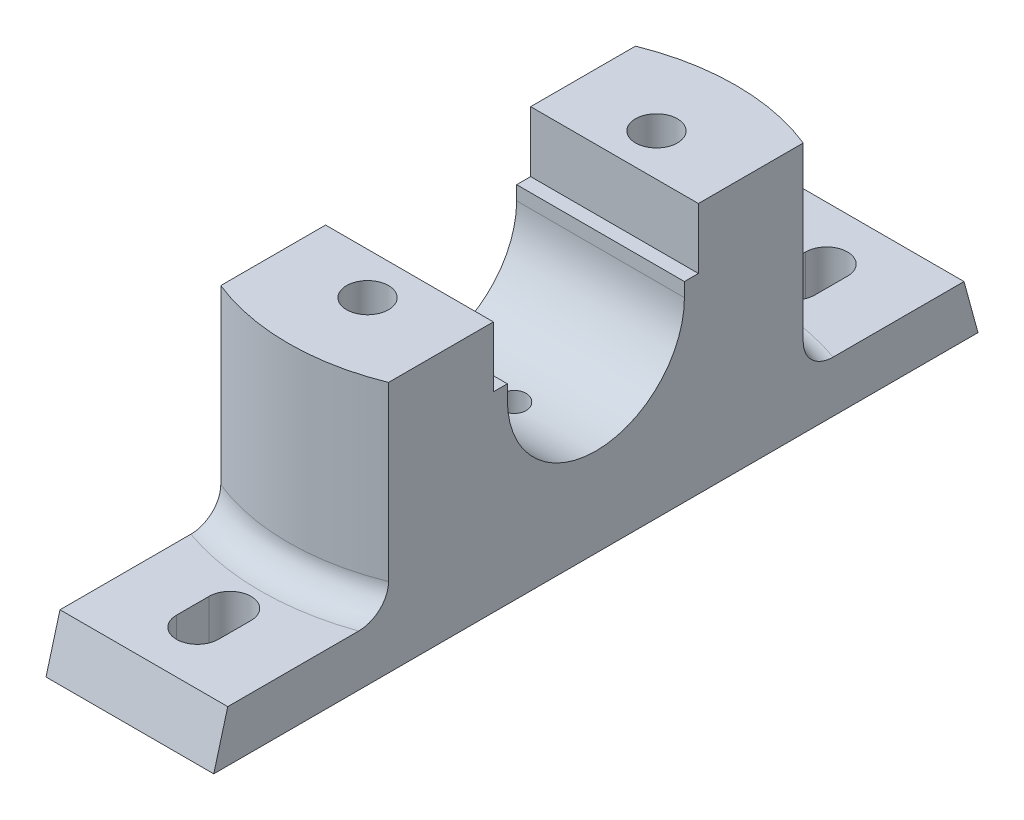
from build123d import *

# Parameters (mm, degrees)
BOSS_EXTRUDE1_DEPTH       = 18
CUT_EXTRUDE1_DEPTH        = 43
SKETCH3_W                 = 20
SKETCH3_H                 = 20
CUT_EXTRUDE4_DEPTH        = 8
SKETCH5_R                 = 4.5
CUT_EXTRUDE5_DEPTH        = 47
CUT_EXTRUDE6_DEPTH        = 55
F_6_0MM_DOWEL_HOLE1_D     = 6
F_6_0MM_DOWEL_HOLE1_DEPTH = 6
F_6_0MM_DOWEL_HOLE1_TIP   = 1.802581857
FILLET1_R                 = 6
FILLET2_R                 = 6


with BuildPart() as part:
    # Sketch1 → Boss-Extrude1 (new body, symmetric)
    with BuildSketch(Plane(origin=(0, 0, 0), x_dir=(0, 0, -1), z_dir=(1, 0, 0))):
        with BuildLine():
            Line((-82, 0), (82, 0))
            Line((82, 0), (79, 11))
            Line((79, 11), (50, 11))
            Line((50, 11), (50, 54))
            Line((50, 54), (22, 54))
            Line((22, 54), (22, 41))
            Line((22, 41), (19, 41))
            Line((19, 41), (19, 38))
            ThreePointArc((19, 38), (0, 19), (-19, 38))
            Line((-19, 38), (-19, 41))
            Line((-19, 41), (-22, 41))
            Line((-22, 41), (-22, 54))
            Line((-22, 54), (-50, 54))
            Line((-50, 54), (-50, 11))
            Line((-50, 11), (-79, 11))
            Line((-79, 11), (-82, 0))
        make_face()
    extrude(amount=BOSS_EXTRUDE1_DEPTH, both=True)

    # Sketch2 → Cut-Extrude1 (cut)
    with BuildSketch(Plane(origin=(0, 54, 0), x_dir=(1, 0, 0), z_dir=(0, 1, 0))):
        with BuildLine():
            Line((-18, 50), (-18, 44.497190923))
            ThreePointArc((-18, 44.497190923), (0, 48), (18, 44.497190923))
            Line((18, 44.497190923), (18, 50))
            Line((18, 50), (-18, 50))
        make_face()
        with BuildLine():
            Line((18, -50), (18, -44.497190923))
            ThreePointArc((18, -44.497190923), (0, -48), (-18, -44.497190923))
            Line((-18, -44.497190923), (-18, -50))
            Line((-18, -50), (18, -50))
        make_face()
    extrude(amount=-CUT_EXTRUDE1_DEPTH, mode=Mode.SUBTRACT)

    # Sketch3 → Cut-Extrude4 (cut)
    with BuildSketch(Plane(origin=(0, 0, 0), x_dir=(-1, 0, 0), z_dir=(0, -1, 0))):
        with Locations((0, 31)):
            Rectangle(SKETCH3_W, SKETCH3_H)
        with Locations((0, -31)):
            Rectangle(SKETCH3_W, SKETCH3_H)
    extrude(amount=-CUT_EXTRUDE4_DEPTH, mode=Mode.SUBTRACT)

    # Sketch5 → Cut-Extrude5 (cut, through all)
    with BuildSketch(Plane(origin=(0, 8, 0), x_dir=(-1, 0, 0), z_dir=(0, -1, 0))):
        with Locations(Location((0, 31, 0), (0, 0, 90))):  # turned: the seam where the file's is
            Circle(SKETCH5_R)
        with Locations(Location((0, -31, 0), (0, 0, 270))):  # turned: the seam where the file's is
            Circle(SKETCH5_R)
    extrude(amount=-CUT_EXTRUDE5_DEPTH, mode=Mode.SUBTRACT)

    # Sketch6 → Cut-Extrude6 (cut, through all)
    with BuildSketch(Plane(origin=(0, 0, 0), x_dir=(-1, 0, 0), z_dir=(0, -1, 0))):
        with BuildLine():
            Line((-4.5, 60.5), (-4.5, 67.5))
            ThreePointArc((-4.5, 67.5), (0, 72), (4.5, 67.5))
            Line((4.5, 67.5), (4.5, 60.5))
            ThreePointArc((4.5, 60.5), (0, 56), (-4.5, 60.5))
        make_face()
        with BuildLine():
            Line((-4.5, -60.5), (-4.5, -67.5))
            ThreePointArc((-4.5, -67.5), (0, -72), (4.5, -67.5))
            Line((4.5, -67.5), (4.5, -60.5))
            ThreePointArc((4.5, -60.5), (0, -56), (-4.5, -60.5))
        make_face()
    extrude(amount=-CUT_EXTRUDE6_DEPTH, mode=Mode.SUBTRACT)

    # Ø6.0mm Dowel Hole1
    with Locations(Plane.ZX.offset(19)):
        with Locations((0, 0)):
            Hole(F_6_0MM_DOWEL_HOLE1_D / 2, depth=F_6_0MM_DOWEL_HOLE1_DEPTH)
            with Locations((0, 0, -(F_6_0MM_DOWEL_HOLE1_DEPTH + F_6_0MM_DOWEL_HOLE1_TIP / 2))):  # 118° drill point
                Cone(0, F_6_0MM_DOWEL_HOLE1_D / 2, F_6_0MM_DOWEL_HOLE1_TIP, mode=Mode.SUBTRACT)

    # Fillet1
    fillet1_edges = [part.edges().sort_by_distance(p)[0] for p in [
        (0, 11, 48),
    ]]
    fillet(fillet1_edges, radius=FILLET1_R)

    # Fillet2
    fillet2_edges = [part.edges().sort_by_distance(p)[0] for p in [
        (0, 11, -48),
    ]]
    fillet(fillet2_edges, radius=FILLET2_R)


solid = part.part
